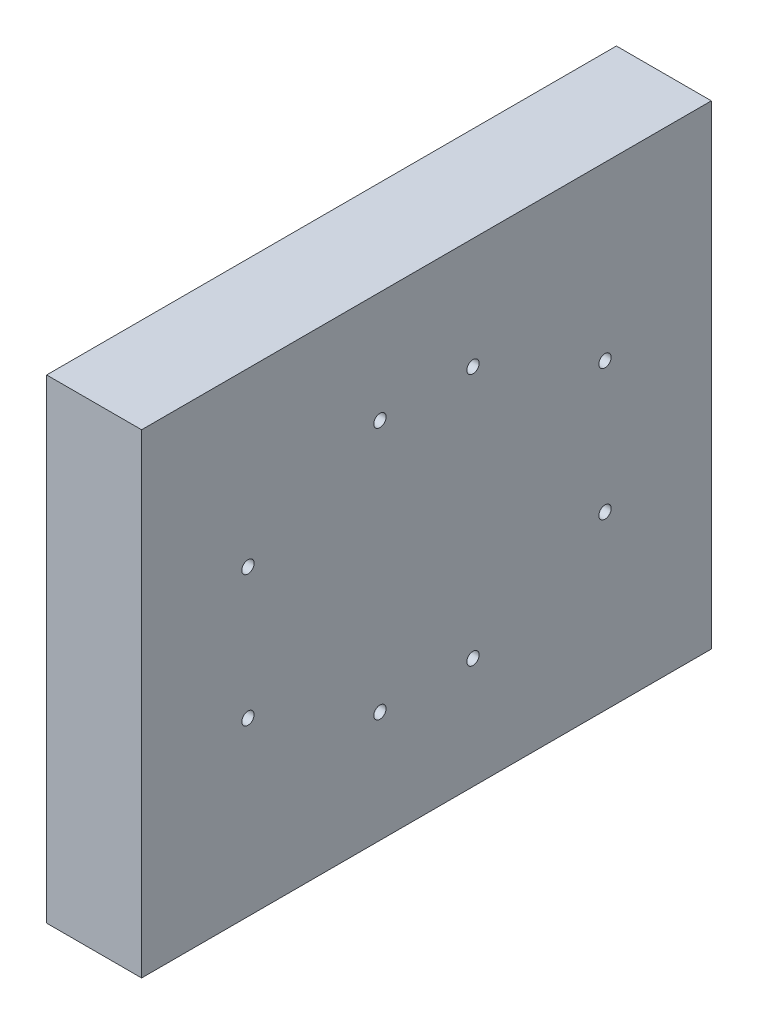
from build123d import *

# Parameters (mm, degrees)
SKETCH1_W           = 152.4
SKETCH1_H           = 127
SKETCH1_R           = 1.651
BOSS_EXTRUDE1_DEPTH = 25.4


with BuildPart() as part:
    # Sketch1 → Boss-Extrude1 (new body)
    with BuildSketch(Plane(origin=(0, 0, 0), x_dir=(0, 0, -1), z_dir=(1, 0, 0))):
        with Locations((76.2, 63.5)):
            Rectangle(SKETCH1_W, SKETCH1_H)
        with Locations((28.448, 81.026)):
            Circle(SKETCH1_R, mode=Mode.SUBTRACT)
        with Locations((28.448, 45.974)):
            Circle(SKETCH1_R, mode=Mode.SUBTRACT)
        with Locations((123.952, 81.026)):
            Circle(SKETCH1_R, mode=Mode.SUBTRACT)
        with Locations((123.952, 45.974)):
            Circle(SKETCH1_R, mode=Mode.SUBTRACT)
        with Locations((63.754, 97.282)):
            Circle(SKETCH1_R, mode=Mode.SUBTRACT)
        with Locations((88.646, 97.282)):
            Circle(SKETCH1_R, mode=Mode.SUBTRACT)
        with Locations((63.754, 29.718)):
            Circle(SKETCH1_R, mode=Mode.SUBTRACT)
        with Locations((88.646, 29.718)):
            Circle(SKETCH1_R, mode=Mode.SUBTRACT)
    extrude(amount=BOSS_EXTRUDE1_DEPTH)


solid = part.part
